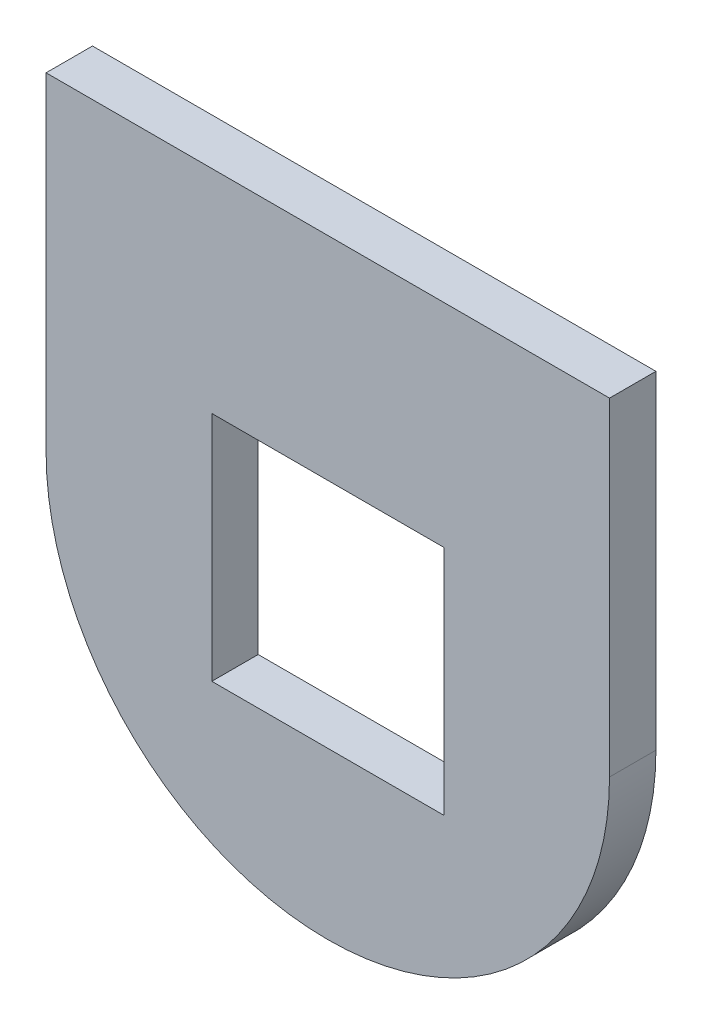
from build123d import *

# Parameters (mm, degrees)
SKETCH1_W           = 85
SKETCH1_H           = 95
BOSS_EXTRUDE1_DEPTH = 7
SKETCH2_W           = 35
SKETCH2_H           = 35
CUT_EXTRUDE1_DEPTH  = 7
CUT_EXTRUDE4_DEPTH  = 10
SKETCH12_W          = 85
SKETCH12_H          = 7
CUT_EXTRUDE9_DEPTH  = 0.5


with BuildPart() as part:
    # Sketch1 → Boss-Extrude1 (new body)
    with BuildSketch(Plane.XY):
        with Locations((42.5, 47.5)):
            Rectangle(SKETCH1_W, SKETCH1_H)
    extrude(amount=BOSS_EXTRUDE1_DEPTH)

    # Sketch2 → Cut-Extrude1 (cut)
    with BuildSketch(Plane.XY.offset(7)):
        with Locations((42.5, 45)):
            Rectangle(SKETCH2_W, SKETCH2_H)
    extrude(amount=-CUT_EXTRUDE1_DEPTH, mode=Mode.SUBTRACT)

    # Sketch7 → Cut-Extrude4 (cut)
    with BuildSketch(Plane(origin=(0, 0, 0), x_dir=(-1, 0, 0), z_dir=(0, 0, -1))):
        with BuildLine():
            Line((-85, 45), (-85, 0))
            Line((-85, 0), (0, 0))
            Line((0, 0), (0, 45))
            ThreePointArc((0, 45), (-42.5, 2.5), (-85, 45))
        make_face()
    extrude(amount=-CUT_EXTRUDE4_DEPTH, mode=Mode.SUBTRACT)

    # Sketch12 → Cut-Extrude9 (cut)
    with BuildSketch(Plane(origin=(0, 95, 0), x_dir=(1, 0, 0), z_dir=(0, 1, 0))):
        with Locations((42.5, -3.5)):
            Rectangle(SKETCH12_W, SKETCH12_H)
    extrude(amount=-CUT_EXTRUDE9_DEPTH, mode=Mode.SUBTRACT)


solid = part.part
